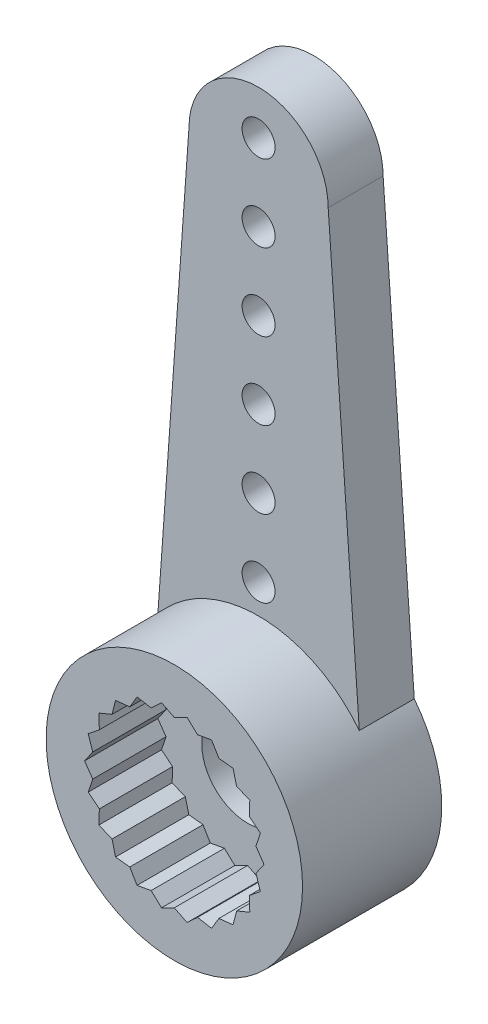
from build123d import *

# Parameters (mm, degrees)
SKETCH1_W                                        = 3.5
SKETCH1_H                                        = 3.8
BOSS_EXTRUDE1_DEPTH                              = 1.5
CUT_EXTRUDE1_DEPTH                               = 2
F_0_9_0_9_DIAMETER_HOLE1_D                       = 0.9
F_0_9_0_9_DIAMETER_HOLE1_DEPTH                   = 3.8
CBORE_FOR_M2_HEX_HEAD_MACHINE_SCREW1_D           = 2.5
CBORE_FOR_M2_HEX_HEAD_MACHINE_SCREW1_DEPTH       = 3.8
CBORE_FOR_M2_HEX_HEAD_MACHINE_SCREW1_CBORE_D     = 4.7
CBORE_FOR_M2_HEX_HEAD_MACHINE_SCREW1_CBORE_DEPTH = 1


with BuildPart() as part:
    # Sketch1 → Revolve1 (revolve)
    with BuildSketch(Plane(origin=(0, 0, 0), x_dir=(1, 0, 0), z_dir=(0, 1, 0))):
        with Locations((1.75, -1.9)):
            Rectangle(SKETCH1_W, SKETCH1_H)
    revolve(axis=Axis((0, 0, 0), (0, 0, 1)))

    # Sketch2 → Boss-Extrude1 (add)
    with BuildSketch(Plane(origin=(0, 0, 0), x_dir=(-1, 0, 0), z_dir=(0, 0, -1))):
        with BuildLine():
            Line((-1.9, 14.1), (-2.75, 2.165063509))
            ThreePointArc((-2.75, 2.165063509), (0, 3.5), (2.75, 2.165063509))
            Line((2.75, 2.165063509), (1.9, 14.1))
            ThreePointArc((1.9, 14.1), (0, 16), (-1.9, 14.1))
        make_face()
    extrude(amount=-BOSS_EXTRUDE1_DEPTH)

    # Sketch3 → Cut-Extrude1 (cut)
    with BuildSketch(Plane.XY.offset(3.8)):
        Polygon((2.06028803, 1.324066719), (1.700436542, 1.473436651), (1.603799186, 1.850882928), (1.216441839, 1.892820449), (1.017380071, 2.227751609), (0.633898253, 2.158859191), (0.348538872, 2.424141105), (0, 2.25), (-0.348538872, 2.424141105), (-0.633898253, 2.158859191), (-1.017380071, 2.227751609), (-1.216441839, 1.892820449), (-1.603799186, 1.850882928), (-1.700436542, 1.473436651), (-2.06028803, 1.324066719), (-2.04667199, 0.934683779), (-2.34986459, 0.689982499), (-2.227098244, 0.320208386), (-2.449069097, 0), (-2.227098244, -0.320208386), (-2.34986459, -0.689982499), (-2.04667199, -0.934683779), (-2.06028803, -1.324066719), (-1.700436542, -1.473436651), (-1.603799186, -1.850882928), (-1.216441839, -1.892820449), (-1.017380071, -2.227751609), (-0.633898253, -2.158859191), (-0.348538872, -2.424141105), (0, -2.25), (0.348538872, -2.424141105), (0.633898253, -2.158859191), (1.017380071, -2.227751609), (1.216441839, -1.892820449), (1.603799186, -1.850882928), (1.700436542, -1.473436651), (2.06028803, -1.324066719), (2.04667199, -0.934683779), (2.34986459, -0.689982499), (2.227098244, -0.320208386), (2.449069097, 0), (2.227098244, 0.320208386), (2.34986459, 0.689982499), (2.04667199, 0.934683779), align=None)
    extrude(amount=-CUT_EXTRUDE1_DEPTH, mode=Mode.SUBTRACT)

    # Ø0.9 (0.9) Diameter Hole1
    with Locations(Plane(origin=(0, 0, 0), x_dir=(-1, 0, 0), z_dir=(0, 0, -1))):
        with Locations((0, 10.6), (0, 12.7), (0, 14.8), (0, 6.4), (0, 8.5), (0, 4.3)):
            Hole(F_0_9_0_9_DIAMETER_HOLE1_D / 2, depth=F_0_9_0_9_DIAMETER_HOLE1_DEPTH)

    # CBORE for M2 Hex Head Machine Screw1
    with Locations(Plane(origin=(0, 0, 0), x_dir=(-1, 0, 0), z_dir=(0, 0, -1))):
        with Locations((0, 0)):
            CounterBoreHole(CBORE_FOR_M2_HEX_HEAD_MACHINE_SCREW1_D / 2, CBORE_FOR_M2_HEX_HEAD_MACHINE_SCREW1_CBORE_D / 2, CBORE_FOR_M2_HEX_HEAD_MACHINE_SCREW1_CBORE_DEPTH, depth=CBORE_FOR_M2_HEX_HEAD_MACHINE_SCREW1_DEPTH)


solid = part.part
